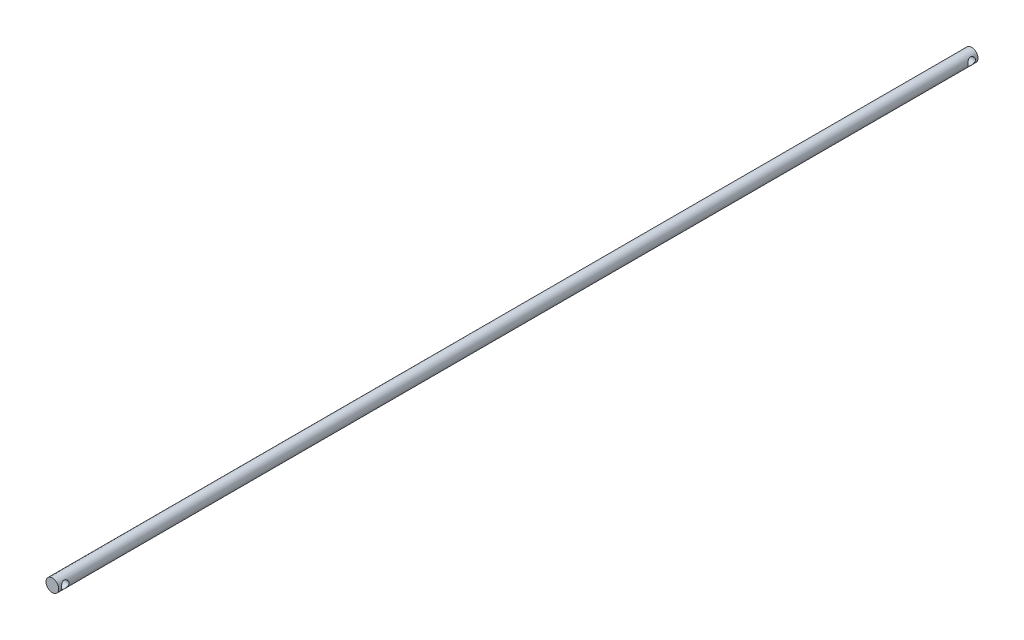
from build123d import *

# Parameters (mm, degrees)
SKETCH2_R               = 2.5
BOSS_EXTRUDE1_DEPTH     = 360
SKETCH3_R               = 1.5
CUT_EXTRUDE1_DEPTH      = 3.5
CUT_EXTRUDE1_DEPTH_BACK = 3.5


with BuildPart() as part:
    # Sketch2 → Boss-Extrude1 (new body)
    with BuildSketch(Plane.XY):
        Circle(SKETCH2_R)
    extrude(amount=BOSS_EXTRUDE1_DEPTH)

    # Sketch3 → Cut-Extrude1 (cut, two sides)
    with BuildSketch(Plane(origin=(0, 0, 0), x_dir=(0, 0, -1), z_dir=(1, 0, 0))) as cut_extrude1_sk:
        with Locations((-357.435271275, 0)):
            Circle(SKETCH3_R)
        with Locations((-2.49563784, 0)):
            Circle(SKETCH3_R)
    extrude(amount=CUT_EXTRUDE1_DEPTH, mode=Mode.SUBTRACT)
    extrude(cut_extrude1_sk.sketch, amount=-CUT_EXTRUDE1_DEPTH_BACK, mode=Mode.SUBTRACT)


solid = part.part
